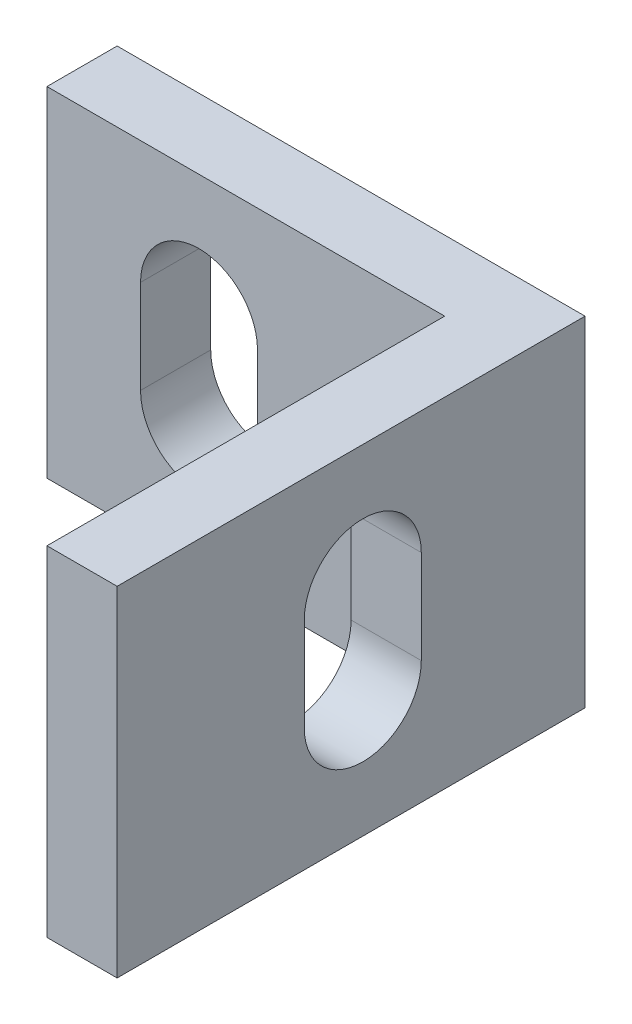
from build123d import *

# Parameters (mm, degrees)
BOSS_EXTRUDE1_DEPTH     = 7.25
CUT_EXTRUDE1_DEPTH      = 18
CUT_EXTRUDE1_DEPTH_BACK = 4
CUT_EXTRUDE2_DEPTH      = 4
CUT_EXTRUDE2_DEPTH_BACK = 18


with BuildPart() as part:
    # Sketch1 → Boss-Extrude1 (new body, symmetric)
    with BuildSketch(Plane(origin=(0, 0, 0), x_dir=(1, 0, 0), z_dir=(0, 1, 0))):
        Polygon((0, 0), (0, -17), (3, -17), (3, 3), (-17, 3), (-17, 0), align=None)
    extrude(amount=BOSS_EXTRUDE1_DEPTH, both=True)

    # Sketch2 → Cut-Extrude1 (cut, two sides)
    with BuildSketch(Plane.XY) as cut_extrude1_sk:
        with BuildLine():
            Line((-8, 2), (-8, -2))
            ThreePointArc((-8, -2), (-10.5, -4.5), (-13, -2))
            Line((-13, -2), (-13, 2))
            ThreePointArc((-13, 2), (-10.5, 4.5), (-8, 2))
        make_face()
    extrude(amount=CUT_EXTRUDE1_DEPTH, mode=Mode.SUBTRACT)
    extrude(cut_extrude1_sk.sketch, amount=-CUT_EXTRUDE1_DEPTH_BACK, mode=Mode.SUBTRACT)

    # Sketch3 → Cut-Extrude2 (cut, two sides)
    with BuildSketch(Plane(origin=(0, 0, 0), x_dir=(0, 0, -1), z_dir=(1, 0, 0))) as cut_extrude2_sk:
        with BuildLine():
            Line((-4, 2), (-4, -2))
            ThreePointArc((-4, -2), (-6.5, -4.5), (-9, -2))
            Line((-9, -2), (-9, 2))
            ThreePointArc((-9, 2), (-6.5, 4.5), (-4, 2))
        make_face()
    extrude(amount=CUT_EXTRUDE2_DEPTH, mode=Mode.SUBTRACT)
    extrude(cut_extrude2_sk.sketch, amount=-CUT_EXTRUDE2_DEPTH_BACK, mode=Mode.SUBTRACT)


solid = part.part
